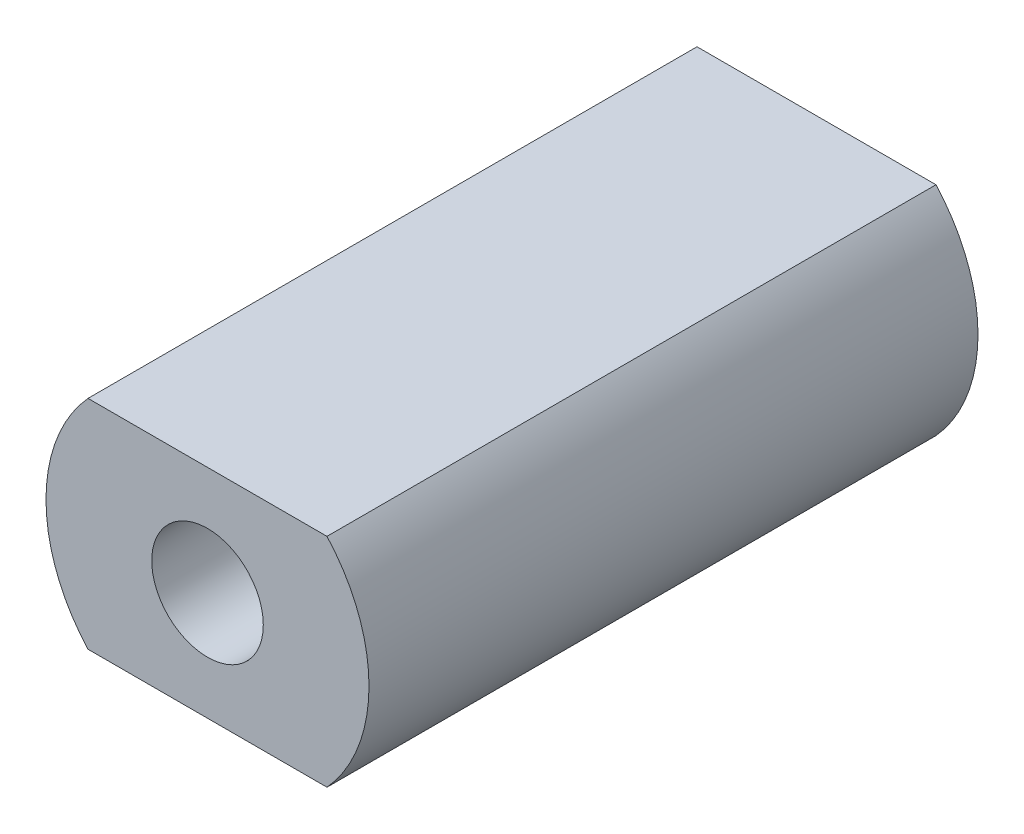
from build123d import *

# Parameters (mm, degrees)
SKETCH1_R           = 0.95
BOSS_EXTRUDE1_DEPTH = 10.370000088


with BuildPart() as part:
    # Sketch1 → Boss-Extrude1 (new body)
    with BuildSketch(Plane.XY):
        with BuildLine():
            Line((-2.034698995, 1.85), (2.034698995, 1.85))
            ThreePointArc((2.034698995, 1.85), (2.75, 0), (2.034698995, -1.85))
            Line((2.034698995, -1.85), (-2.034698995, -1.85))
            ThreePointArc((-2.034698995, -1.85), (-2.75, 0), (-2.034698995, 1.85))
        make_face()
        Circle(SKETCH1_R, mode=Mode.SUBTRACT)
    extrude(amount=BOSS_EXTRUDE1_DEPTH)


solid = part.part
